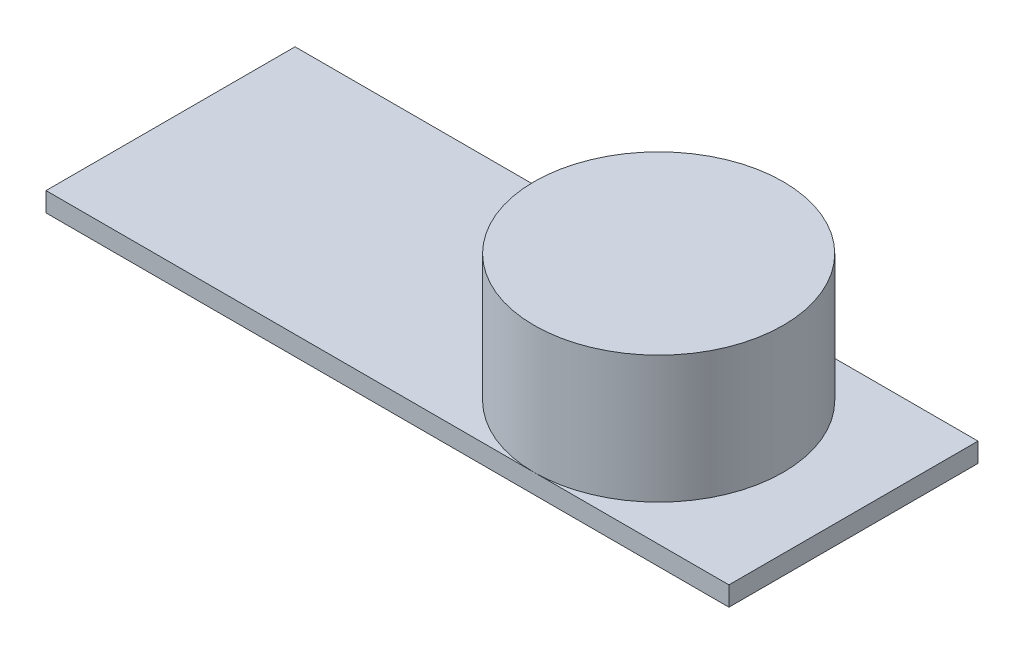
from build123d import *

# Parameters (mm, degrees)
SKETCH1_R                = 2.25
BOSS_EXTRUDE1_DEPTH      = 1.15
BOSS_EXTRUDE1_DEPTH_BACK = 1.15
BOSS_EXTRUDE2_DEPTH      = 1.8
CHAMFER2_SIZE            = 1.45
CHAMFER4_SIZE            = 1.45


with BuildPart() as part:
    # Sketch1 → Boss-Extrude1 (new body, two sides)
    with BuildSketch(Plane(origin=(0, 0, 0), x_dir=(1, 0, 0), z_dir=(0, 1, 0))) as boss_extrude1_sk:
        Circle(SKETCH1_R)
    extrude(amount=BOSS_EXTRUDE1_DEPTH)
    extrude(boss_extrude1_sk.sketch, amount=-BOSS_EXTRUDE1_DEPTH_BACK)

    # Sketch2 → Boss-Extrude2 (add)
    with BuildSketch(Plane.XZ.offset(1.15)):
        Polygon((-3.52, 2.25), (3.52, 2.25), (3.52, -2.25), (-3.52, -2.25), (-8.82, -2.25), (-8.82, 2.25), align=None)
    extrude(amount=BOSS_EXTRUDE2_DEPTH)

    # Chamfer2
    chamfer2_edges = [part.edges().sort_by_distance(p)[0] for p in [
        (-2.65, -2.95, 2.25),
    ]]
    chamfer(chamfer2_edges, length=CHAMFER2_SIZE)

    # Chamfer4
    chamfer4_edges = [part.edges().sort_by_distance(p)[0] for p in [
        (3.52, -2.95, -0.725),
    ]]
    chamfer(chamfer4_edges, length=CHAMFER4_SIZE)


solid = part.part
